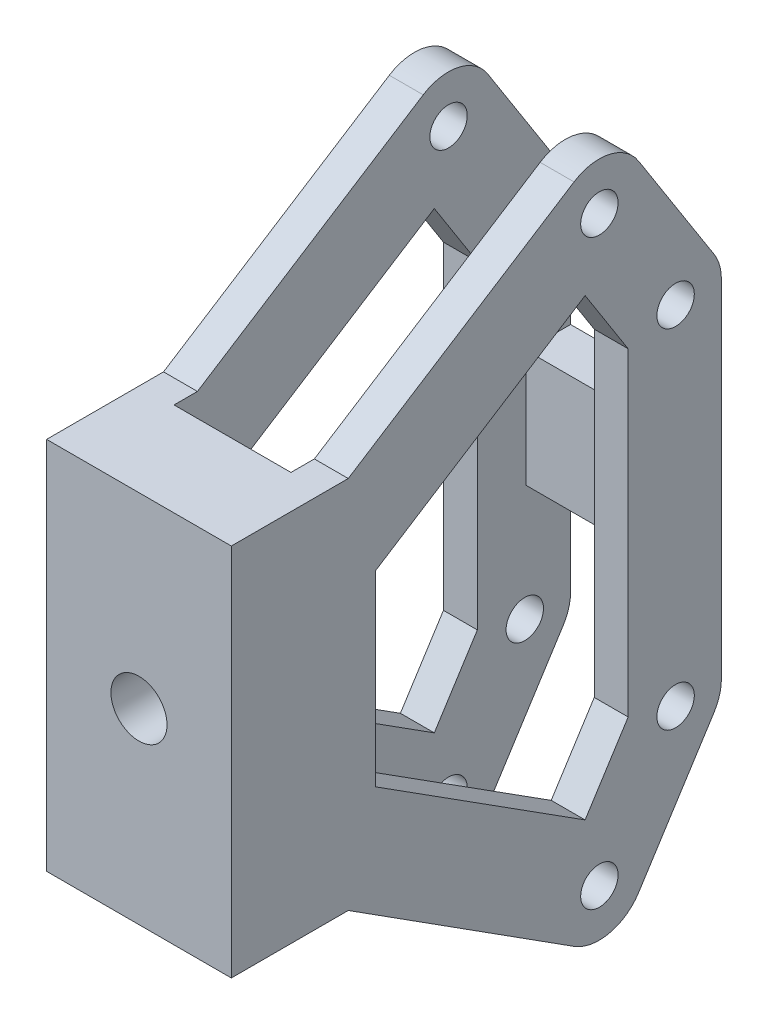
from build123d import *

# Parameters (mm, degrees)
SKETCH1_R               = 4
BOSS_EXTRUDE1_DEPTH     = 39.5
SKETCH2_W               = 25
SKETCH2_H               = 75.25
CUT_EXTRUDE1_DEPTH      = 105.5
CUT_EXTRUDE1_DEPTH_BACK = 117.5
CUT_EXTRUDE2_DEPTH      = 43.5
SKETCH4_R               = 6
CUT_EXTRUDE3_DEPTH      = 41


with BuildPart() as part:
    # Sketch1 → Boss-Extrude1 (new body)
    with BuildSketch(Plane(origin=(0, 0, 0), x_dir=(0, 0, -1), z_dir=(1, 0, 0))):
        with BuildLine():
            Line((0, -40), (0, 40))
            Line((0, 40), (25, 40))
            Line((25, 40), (73.280107592, 70.785366831))
            ThreePointArc((73.280107592, 70.785366831), (80.81695996, 72.117470486), (87.088258906, 67.730050596))
            Line((87.088258906, 67.730050596), (103.222887942, 42.426417539))
            ThreePointArc((103.222887942, 42.426417539), (104.391084837, 39.850237691), (104.791154167, 37.05))
            Line((104.791154167, 37.05), (104.791154167, -37.05))
            ThreePointArc((104.791154167, -37.05), (104.391084837, -39.850237691), (103.222887942, -42.426417539))
            Line((103.222887942, -42.426417539), (87.088258906, -67.730050596))
            ThreePointArc((87.088258906, -67.730050596), (80.81695996, -72.117470486), (73.280107592, -70.785366831))
            Line((73.280107592, -70.785366831), (25, -40))
            Line((25, -40), (0, -40))
        make_face()
        with Locations((78.7, 62.25)):
            Circle(SKETCH1_R, mode=Mode.SUBTRACT)
        with Locations((95, 37.153633057)):
            Circle(SKETCH1_R, mode=Mode.SUBTRACT)
        with Locations((95, -37.153633057)):
            Circle(SKETCH1_R, mode=Mode.SUBTRACT)
        with Locations((78.7, -62.25)):
            Circle(SKETCH1_R, mode=Mode.SUBTRACT)
        Polygon((30.81, -20), (30.81, 20), (75.651092334, 48.552793879), (84.857166207, 34.095), (84.857166207, -34.095), (75.651092334, -48.552793879), align=None, mode=Mode.SUBTRACT)
    extrude(amount=BOSS_EXTRUDE1_DEPTH)

    # Sketch2 → Cut-Extrude1 (cut, two sides)
    with BuildSketch(Plane(origin=(0, 0, 0), x_dir=(1, 0, 0), z_dir=(0, 1, 0))) as cut_extrude1_sk:
        with Locations((19.75, 57.625)):
            Rectangle(SKETCH2_W, SKETCH2_H)
    extrude(amount=CUT_EXTRUDE1_DEPTH, mode=Mode.SUBTRACT)
    extrude(cut_extrude1_sk.sketch, amount=-CUT_EXTRUDE1_DEPTH_BACK, mode=Mode.SUBTRACT)

    # Sketch3 → Cut-Extrude2 (cut)
    with BuildSketch(Plane(origin=(0, 0, -104.791154167), x_dir=(-1, 0, 0), z_dir=(0, 0, -1))):
        Polygon((-7.25, -37.05), (-7.25, -12.5), (-32.25, -12.5), (-32.25, -37.05), (-32.25, -54.930146657), (-7.25, -54.930146657), align=None)
        Polygon((-32.25, 37.05), (-32.25, 12.5), (-7.25, 12.5), (-7.25, 37.05), (-7.25, 54.930146657), (-32.25, 54.930146657), align=None)
    extrude(amount=-CUT_EXTRUDE2_DEPTH, mode=Mode.SUBTRACT)

    # Sketch4 → Cut-Extrude3 (cut)
    with BuildSketch(Plane.XY):
        with Locations((19.75, 0)):
            Circle(SKETCH4_R)
    extrude(amount=-CUT_EXTRUDE3_DEPTH, mode=Mode.SUBTRACT)


solid = part.part
